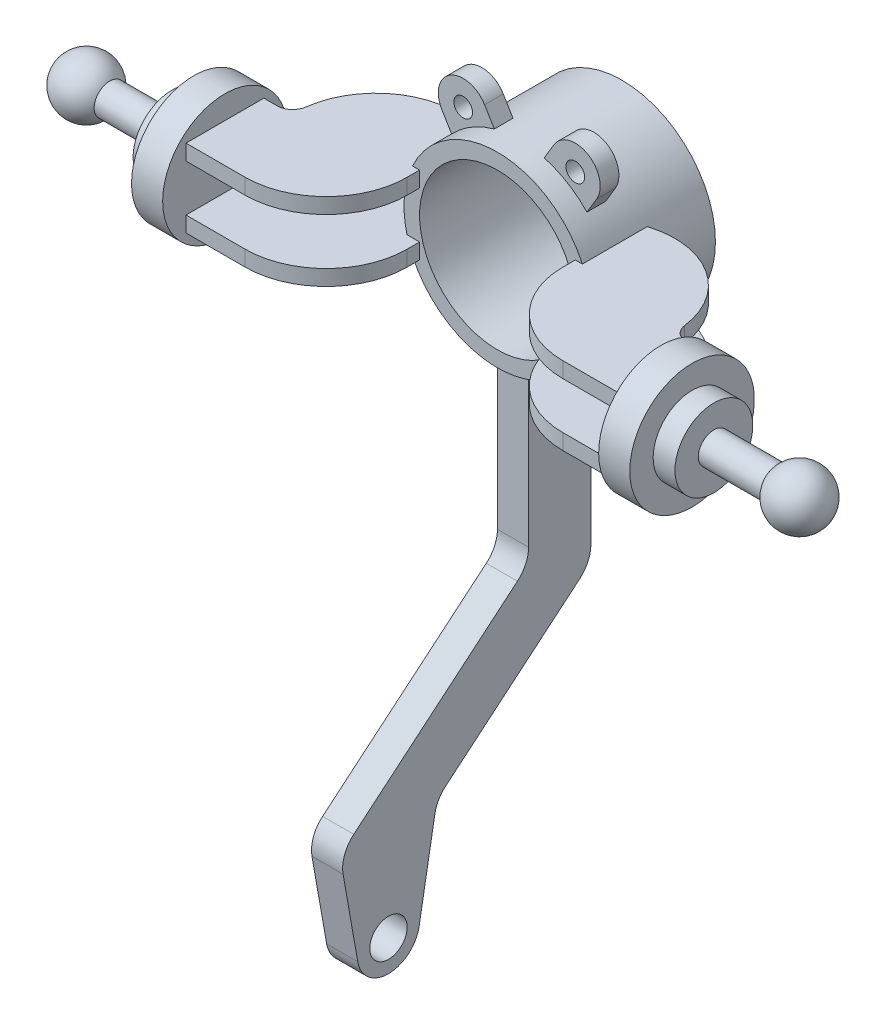
from build123d import *

# Parameters (mm, degrees)
SKETCH1_R               = 30
BOSS_EXTRUDE1_DEPTH     = 20
SKETCH2_R               = 6
BOSS_EXTRUDE2_DEPTH     = 5
BOSS_EXTRUDE3_DEPTH     = 2.5
SKETCH8_R               = 3
BOSS_EXTRUDE4_DEPTH     = 3
MIRROR2_COPY_1_DEPTH    = 2.5
SKETCH3_R               = 25
CUT_EXTRUDE1_DEPTH      = 55.706602517
CUT_EXTRUDE1_DEPTH_BACK = 41.0000001
FILLET1_R               = 5


with BuildPart() as part:
    # Sketch1 → Boss-Extrude1 (new body, symmetric)
    with BuildSketch(Plane.XY):
        Circle(SKETCH1_R)
    extrude(amount=BOSS_EXTRUDE1_DEPTH, both=True)

    # Sketch2 → Boss-Extrude2 (add, symmetric)
    with BuildSketch(Plane(origin=(0, 0, 0), x_dir=(0, 0, -1), z_dir=(1, 0, 0))):
        with BuildLine():
            Line((-15, 0), (5, 0))
            Line((5, 0), (5, -89.20774256))
            ThreePointArc((5, -89.20774256), (4.06307787, -93.433925178), (1.427876097, -96.868186992))
            Line((1.427876097, -96.868186992), (-41.654587977, -133.018666706))
            ThreePointArc((-41.654587977, -133.018666706), (-43.886965918, -135.679111138), (-45.07478941, -138.942629361))
            Line((-45.07478941, -138.942629361), (-50.15192247, -167.736481777))
            ThreePointArc((-50.15192247, -167.736481777), (-60, -176), (-69.84807753, -167.736481777))
            Line((-69.84807753, -167.736481777), (-74.554680047, -141.044012488))
            ThreePointArc((-74.554680047, -141.044012488), (-74.103528725, -135.887329278), (-71.134478614, -131.64708628))
            Line((-71.134478614, -131.64708628), (-18.572123903, -87.542033829))
            ThreePointArc((-18.572123903, -87.542033829), (-15.93692213, -84.107772015), (-15, -79.881589397))
            Line((-15, -79.881589397), (-15, 0))
        make_face()
        with Locations((-60, -166)):
            Circle(SKETCH2_R, mode=Mode.SUBTRACT)
    extrude(amount=BOSS_EXTRUDE2_DEPTH, both=True)

    # Sketch5 → Boss-Extrude3 (add, symmetric)
    with BuildSketch(Plane(origin=(0, -10, 10), x_dir=(1, 0, 0), z_dir=(0, 1, 0))):
        with BuildLine():
            Line((60.980762114, -15), (70, -15))
            Line((70, -15), (70, -40))
            Line((70, -40), (51, -40))
            ThreePointArc((51, -40), (32.615223689, -32.384776311), (25, -14))
            Line((25, -14), (25, 10))
            ThreePointArc((25, 10), (49.835639165, 7.351904144), (60.980762114, -15))
        make_face()
    boss_extrude3 = extrude(amount=BOSS_EXTRUDE3_DEPTH, both=True)

    # Mirror1: Boss-Extrude3 across plane
    add(boss_extrude3.mirror(Plane.ZX))

    # Sketch7 → Revolve1 (revolve)
    with BuildSketch(Plane.XZ, mode=Mode.PRIVATE) as revolve1_sk:
        with BuildLine():
            Line((70, 17.5), (80, 17.5))
            Line((80, 17.5), (80, 25))
            Line((80, 25), (87, 25))
            Line((87, 25), (87, 32.5))
            Line((87, 32.5), (107, 32.5))
            ThreePointArc((107, 32.5), (117.095800854, 28.88751392), (123.483314774, 37.5))
            Line((123.483314774, 37.5), (70, 37.5))
            Line((70, 37.5), (70, 17.5))
        make_face()
    revolve1 = revolve(revolve1_sk.sketch.rotate(Axis((70, 0, 37.5), (1, 0, 0)), 180), axis=Axis((70, 0, 37.5), (1, 0, 0)))  # turned: the seam where the file's is

    # Sketch8 → Boss-Extrude4 (add, symmetric)
    with BuildSketch(Plane.XY.offset(10)):
        with BuildLine():
            Line((24.859943406, 25.884033957), (21.735901111, 20.677296799))
            ThreePointArc((21.735901111, 20.677296799), (15.434872663, 25.724787771), (8.0160143, 28.909228885))
            Line((8.0160143, 28.909228885), (11.140056594, 34.115966043))
            ThreePointArc((11.140056594, 34.115966043), (22.115966043, 36.859943406), (24.859943406, 25.884033957))
        make_face()
        with Locations((18, 30)):
            Circle(SKETCH8_R, mode=Mode.SUBTRACT)
    boss_extrude4 = extrude(amount=BOSS_EXTRUDE4_DEPTH, both=True)

    # Mirror2: Boss-Extrude4, Revolve1, Boss-Extrude3 across plane
    add(boss_extrude4.mirror(Plane(origin=(0, 0, 0), x_dir=(0, 0, 1), z_dir=(1, 0, 0))))
    add(revolve1.mirror(Plane(origin=(0, 0, 0), x_dir=(0, 0, 1), z_dir=(1, 0, 0))))
    add(boss_extrude3.mirror(Plane(origin=(0, 0, 0), x_dir=(0, 0, 1), z_dir=(1, 0, 0))))

    # Mirror2 copy 1 sketch → Mirror2 copy 1 (add, symmetric)
    with BuildSketch(Plane(origin=(0, 10, 10), x_dir=(-1, 0, 0), z_dir=(0, -1, 0))):
        with BuildLine():
            Line((60.980762114, -15), (70, -15))
            Line((70, -15), (70, -40))
            Line((70, -40), (51, -40))
            ThreePointArc((51, -40), (32.615223689, -32.384776311), (25, -14))
            Line((25, -14), (25, 10))
            ThreePointArc((25, 10), (49.835639165, 7.351904144), (60.980762114, -15))
        make_face()
    extrude(amount=MIRROR2_COPY_1_DEPTH, both=True)

    # Sketch3 → Cut-Extrude1 (cut, two sides)
    with BuildSketch(Plane.XY.offset(20)) as cut_extrude1_sk:
        Circle(SKETCH3_R)
    extrude(amount=CUT_EXTRUDE1_DEPTH, mode=Mode.SUBTRACT)
    extrude(cut_extrude1_sk.sketch, amount=-CUT_EXTRUDE1_DEPTH_BACK, mode=Mode.SUBTRACT)

    # Fillet1
    fillet1_edges = [part.edges().sort_by_distance(p)[0] for p in [
        (-60.980762114, -10, 25),
        (-60.980762114, 10, 25),
        (60.980762114, -10, 25),
        (60.980762114, 10, 25),
    ]]
    fillet(fillet1_edges, radius=FILLET1_R)


solid = part.part
